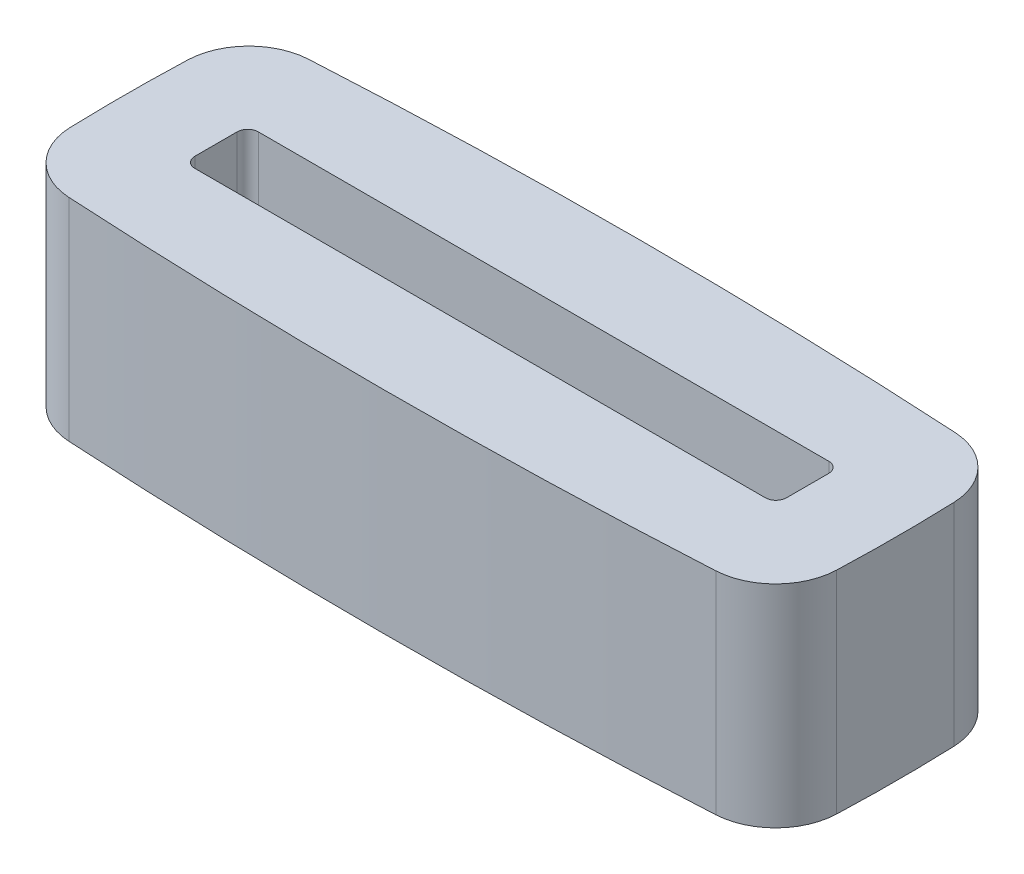
from build123d import *

# Parameters (mm, degrees)
SKETCH_1_W      = 28
SKETCH_1_H      = 3
EXTRUDE_1_DEPTH = 10
FILLET_1_R      = 3
FILLET_2_R      = 0.5


with BuildPart() as part:
    # Эскиз1 → Бобышка-Вытянуть1 (new body)
    with BuildSketch(Plane(origin=(0, 0, 0), x_dir=(1, 0, 0), z_dir=(0, 1, 0))):
        with BuildLine():
            ThreePointArc((-25.941942596, 6.415014515), (-7.956456947, 7.015014515), (10.029028702, 6.415014515))
            ThreePointArc((10.029028702, 6.415014515), (10.229028702, 0.915014515), (10.029028702, -4.584985485))
            ThreePointArc((10.029028702, -4.584985485), (-7.970971298, -5.184985485), (-25.970971298, -4.584985485))
            ThreePointArc((-25.970971298, -4.584985485), (-26.141942596, 0.915504007), (-25.941942596, 6.415014515))
        make_face()
        with Locations((-7.970971298, 0.915014515)):
            Rectangle(SKETCH_1_W, SKETCH_1_H, mode=Mode.SUBTRACT)
    extrude(amount=EXTRUDE_1_DEPTH)

    # Скругление1
    fillet_1_edges = [part.edges().sort_by_distance(p)[0] for p in [
        (-25.941942596, 5, -6.415014515),
        (10.029028702, 5, -6.415014515),
        (10.029028702, 5, 4.584985485),
        (-25.970971298, 5, 4.584985485),
    ]]
    fillet(fillet_1_edges, radius=FILLET_1_R)

    # Скругление2
    fillet_2_edges = [part.edges().sort_by_distance(p)[0] for p in [
        (-21.970971298, 5, -2.415014515),
        (-21.970971298, 5, 0.584985485),
        (6.029028702, 5, 0.584985485),
        (6.029028702, 5, -2.415014515),
    ]]
    fillet(fillet_2_edges, radius=FILLET_2_R)


solid = part.part
